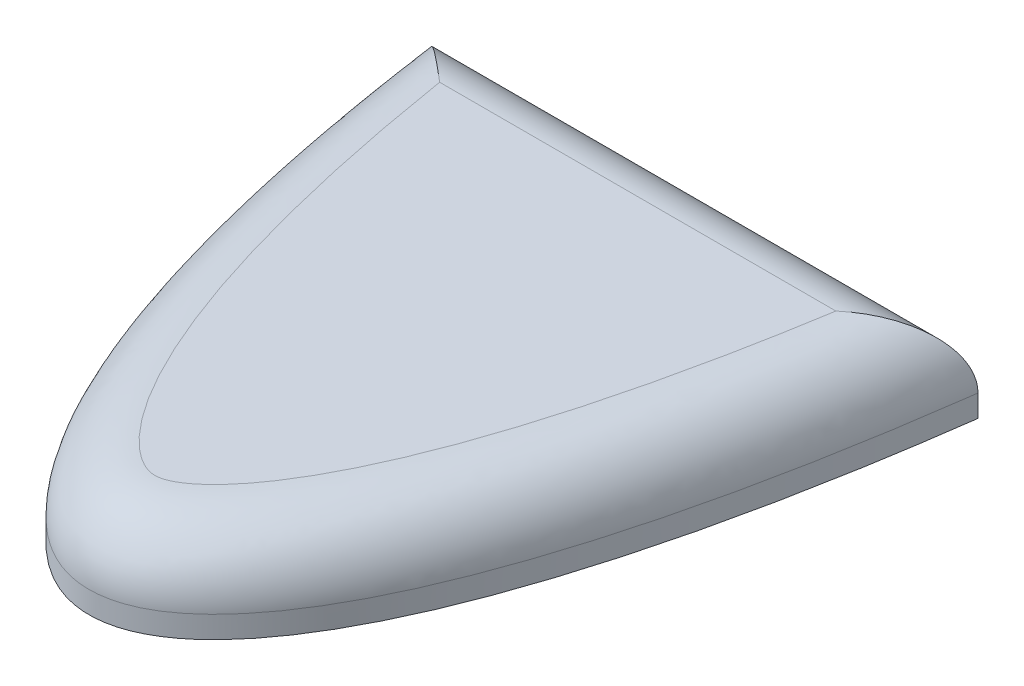
from build123d import *

# Parameters (mm, degrees)
BOSS_EXTRUDE1_DEPTH = 4
FILLET1_R           = 3
SKETCH2_R           = 1.75
BOSS_EXTRUDE2_DEPTH = 2
BOSS_EXTRUDE3_START = -1
SKETCH3_R           = 2
BOSS_EXTRUDE3_DEPTH = 1


with BuildPart() as part:
    # Sketch1 → Boss-Extrude1 (new body)
    with BuildSketch(Plane(origin=(0, 0, 0), x_dir=(1, 0, 0), z_dir=(0, 1, 0))):
        with BuildLine():
            Line((-12.5, 9.463815789), (12.5, 9.463815789))
            add(Edge.make_bspline(
                [(12.5, 9.463815789), (7.5, -27.869517544), (-7.5, -27.869517544), (-12.5, 9.463815789)],
                knots=[0, 0, 0, 0, 1, 1, 1, 1], degree=3))
        make_face()
    extrude(amount=BOSS_EXTRUDE1_DEPTH)

    # Fillet1
    fillet1_edges = [part.edges().sort_by_distance(p)[0] for p in [
        (0, 4, -9.463815789),
        (0.023803991, 4, 18.536113697),
    ]]
    fillet(fillet1_edges, radius=FILLET1_R)

    # Sketch2 → Boss-Extrude2 (add)
    with BuildSketch(Plane.XZ):
        with Locations((0, 6.536184211)):
            Circle(SKETCH2_R)
    extrude(amount=BOSS_EXTRUDE2_DEPTH)

    # Sketch3 → Boss-Extrude3 (add)
    with BuildSketch(Plane.XZ.offset(2).offset(BOSS_EXTRUDE3_START)):
        with Locations((0, 6.536184211)):
            Circle(SKETCH3_R)
    extrude(amount=BOSS_EXTRUDE3_DEPTH)


solid = part.part
